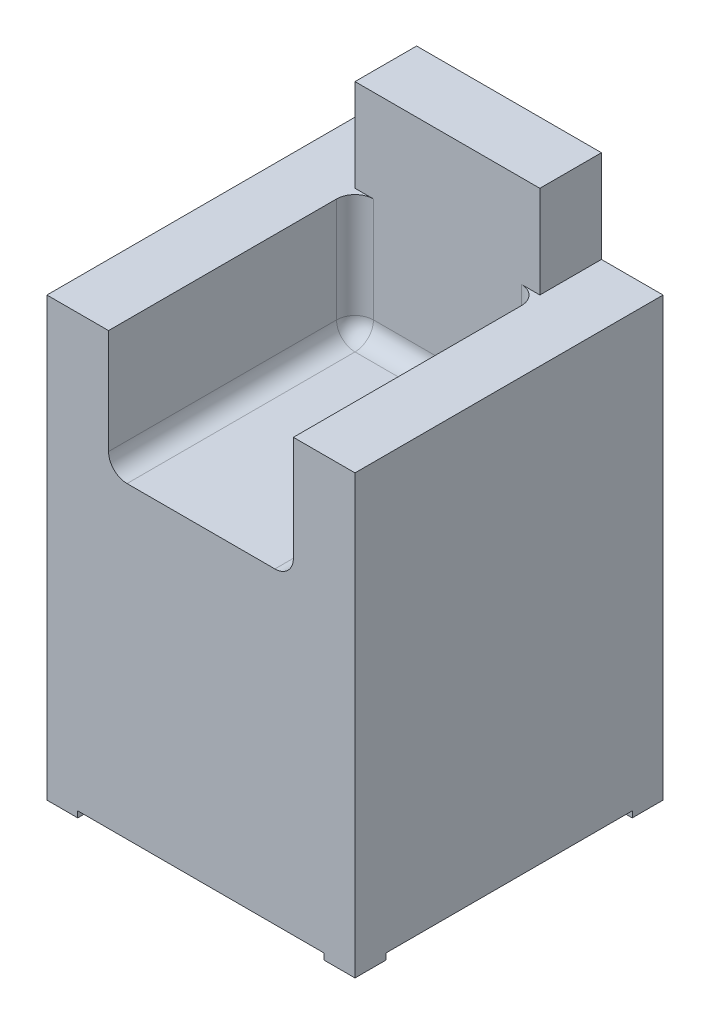
from build123d import *

# Parameters (mm, degrees)
SKETCH1_W           = 500
SKETCH1_H           = 500
BOSS_EXTRUDE1_DEPTH = 250
SKETCH2_W           = 500
SKETCH2_H           = 100
BOSS_EXTRUDE2_DEPTH = 350
SKETCH3_W           = 100
SKETCH3_H           = 400
BOSS_EXTRUDE3_DEPTH = 200
SKETCH4_W           = 100
SKETCH4_H           = 400
BOSS_EXTRUDE4_DEPTH = 200
SKETCH5_W           = 100
SKETCH5_H           = 150
CUT_EXTRUDE4_DEPTH  = 200
SKETCH8_W           = 100
SKETCH8_H           = 150
CUT_EXTRUDE5_DEPTH  = 200
FILLET4_R           = 30
FILLET5_R           = 30
FILLET6_R           = 30
SKETCH9_W           = 50
SKETCH9_H           = 50
BOSS_EXTRUDE5_DEPTH = 10


with BuildPart() as part:
    # Sketch1 → Boss-Extrude1 (new body, symmetric)
    with BuildSketch(Plane(origin=(0, 0, 0), x_dir=(1, 0, 0), z_dir=(0, 1, 0))):
        with Locations((-250, -250)):
            Rectangle(SKETCH1_W, SKETCH1_H)
    extrude(amount=BOSS_EXTRUDE1_DEPTH, both=True)

    # Sketch2 → Boss-Extrude2 (add)
    with BuildSketch(Plane(origin=(0, 250, 0), x_dir=(1, 0, 0), z_dir=(0, 1, 0))):
        with Locations((-250, -50)):
            Rectangle(SKETCH2_W, SKETCH2_H)
    extrude(amount=BOSS_EXTRUDE2_DEPTH)

    # Sketch3 → Boss-Extrude3 (add)
    with BuildSketch(Plane(origin=(0, 250, 0), x_dir=(1, 0, 0), z_dir=(0, 1, 0))):
        with Locations((-450, -300)):
            Rectangle(SKETCH3_W, SKETCH3_H)
    extrude(amount=BOSS_EXTRUDE3_DEPTH)

    # Sketch4 → Boss-Extrude4 (add)
    with BuildSketch(Plane(origin=(0, 250, 0), x_dir=(1, 0, 0), z_dir=(0, 1, 0))):
        with Locations((-50, -300)):
            Rectangle(SKETCH4_W, SKETCH4_H)
    extrude(amount=BOSS_EXTRUDE4_DEPTH)

    # Sketch5 → Cut-Extrude4 (cut)
    with BuildSketch(Plane.XY.offset(100)):
        with Locations((-450, 525)):
            Rectangle(SKETCH5_W, SKETCH5_H)
    extrude(amount=-CUT_EXTRUDE4_DEPTH, mode=Mode.SUBTRACT)

    # Sketch8 → Cut-Extrude5 (cut)
    with BuildSketch(Plane.XY.offset(100)):
        with Locations((-50, 525)):
            Rectangle(SKETCH8_W, SKETCH8_H)
    extrude(amount=-CUT_EXTRUDE5_DEPTH, mode=Mode.SUBTRACT)

    # Fillet4
    fillet4_edges = [part.edges().sort_by_distance(p)[0] for p in [
        (-400, 250, 300),
    ]]
    fillet(fillet4_edges, radius=FILLET4_R)

    # Fillet5
    fillet5_edges = [part.edges().sort_by_distance(p)[0] for p in [
        (-100, 250, 300),
    ]]
    fillet(fillet5_edges, radius=FILLET5_R)

    # Fillet6
    fillet6_edges = [part.edges().sort_by_distance(p)[0] for p in [
        (-108.786796564, 258.786796564, 100),
        (-400, 365, 100),
        (-100, 365, 100),
        (-250, 250, 100),
        (-391.213203436, 258.786796564, 100),
    ]]
    fillet(fillet6_edges, radius=FILLET6_R)

    # Sketch9 → Boss-Extrude5 (add)
    with BuildSketch(Plane.XZ.offset(250)):
        with Locations((-475, 475)):
            Rectangle(SKETCH9_W, SKETCH9_H)
        with Locations((-475, 25)):
            Rectangle(SKETCH9_W, SKETCH9_H)
        with Locations((-25, 25)):
            Rectangle(SKETCH9_W, SKETCH9_H)
        with Locations((-25, 475)):
            Rectangle(SKETCH9_W, SKETCH9_H)
    extrude(amount=BOSS_EXTRUDE5_DEPTH)


solid = part.part
